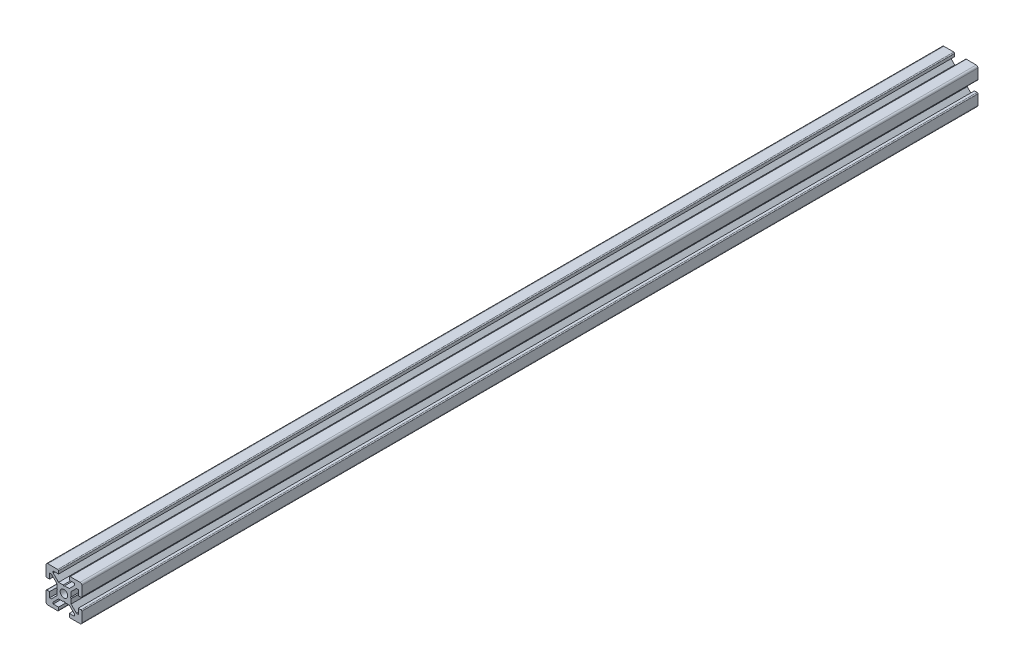
from build123d import *

# Parameters (mm, degrees)
SCHIZZO1_R                   = 2.1
ESTRUSIONE_ESTRUSIONE1_DEPTH = 500


with BuildPart() as part:
    # Schizzo1 → Estrusione-Estrusione1 (new body)
    with BuildSketch(Plane.XY):
        with BuildLine():
            Line((-3.6, 0), (-4, 0.4))
            Line((-4, 0.4), (-4, 3))
            Line((-4, 3), (-7, 6))
            Line((-7, 6), (-8, 6))
            Line((-8, 6), (-8, 3))
            Line((-8, 3), (-9.5, 3))
            ThreePointArc((-9.5, 3), (-9.853553391, 3.146446609), (-10, 3.5))
            Line((-10, 3.5), (-10, 9))
            ThreePointArc((-10, 9), (-9.707106781, 9.707106781), (-9, 10))
            Line((-9, 10), (-3.5, 10))
            ThreePointArc((-3.5, 10), (-3.146446609, 9.853553391), (-3, 9.5))
            Line((-3, 9.5), (-3, 8))
            Line((-3, 8), (-6, 8))
            Line((-6, 8), (-6, 7))
            Line((-6, 7), (-3, 4))
            Line((-3, 4), (-0.4, 4))
            Line((-0.4, 4), (0, 3.6))
            Line((0, 3.6), (0.4, 4))
            Line((0.4, 4), (3, 4))
            Line((3, 4), (6, 7))
            Line((6, 7), (6, 8))
            Line((6, 8), (3, 8))
            Line((3, 8), (3, 9.5))
            ThreePointArc((3, 9.5), (3.146446609, 9.853553391), (3.5, 10))
            Line((3.5, 10), (9, 10))
            ThreePointArc((9, 10), (9.707106781, 9.707106781), (10, 9))
            Line((10, 9), (10, 3.5))
            ThreePointArc((10, 3.5), (9.853553391, 3.146446609), (9.5, 3))
            Line((9.5, 3), (8, 3))
            Line((8, 3), (8, 6))
            Line((8, 6), (7, 6))
            Line((7, 6), (4, 3))
            Line((4, 3), (4, 0.4))
            Line((4, 0.4), (3.6, 0))
            Line((3.6, 0), (4, -0.4))
            Line((4, -0.4), (4, -3))
            Line((4, -3), (7, -6))
            Line((7, -6), (8, -6))
            Line((8, -6), (8, -3))
            Line((8, -3), (9.5, -3))
            ThreePointArc((9.5, -3), (9.853553391, -3.146446609), (10, -3.5))
            Line((10, -3.5), (10, -9))
            ThreePointArc((10, -9), (9.707106781, -9.707106781), (9, -10))
            Line((9, -10), (3.5, -10))
            ThreePointArc((3.5, -10), (3.146446609, -9.853553391), (3, -9.5))
            Line((3, -9.5), (3, -8))
            Line((3, -8), (6, -8))
            Line((6, -8), (6, -7))
            Line((6, -7), (3, -4))
            Line((3, -4), (0.4, -4))
            Line((0.4, -4), (0, -3.6))
            Line((0, -3.6), (-0.4, -4))
            Line((-0.4, -4), (-3, -4))
            Line((-3, -4), (-6, -7))
            Line((-6, -7), (-6, -8))
            Line((-6, -8), (-3, -8))
            Line((-3, -8), (-3, -9.5))
            ThreePointArc((-3, -9.5), (-3.146446609, -9.853553391), (-3.5, -10))
            Line((-3.5, -10), (-9, -10))
            ThreePointArc((-9, -10), (-9.707106781, -9.707106781), (-10, -9))
            Line((-10, -9), (-10, -3.5))
            ThreePointArc((-10, -3.5), (-9.853553391, -3.146446609), (-9.5, -3))
            Line((-9.5, -3), (-8, -3))
            Line((-8, -3), (-8, -6))
            Line((-8, -6), (-7, -6))
            Line((-7, -6), (-4, -3))
            Line((-4, -3), (-4, -0.4))
            Line((-4, -0.4), (-3.6, 0))
        make_face()
        Circle(SCHIZZO1_R, mode=Mode.SUBTRACT)
    extrude(amount=ESTRUSIONE_ESTRUSIONE1_DEPTH)


solid = part.part
